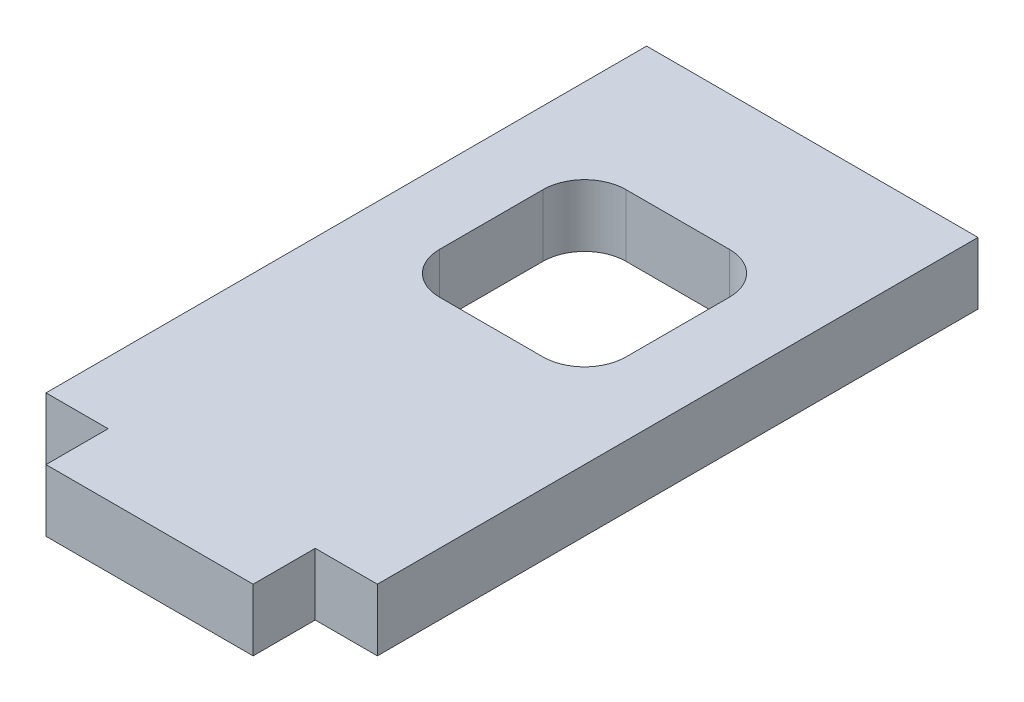
from build123d import *

# Parameters (mm, degrees)
SKETCH1_W               = 16
SKETCH1_H               = 29
BOSS_EXTRUDE1_DEPTH     = 1.5
SKETCH2_W               = 10
SKETCH2_H               = 3
BOSS_EXTRUDE2_DEPTH     = 1.5
SKETCH3_W               = 9
SKETCH3_H               = 9
CUT_EXTRUDE1_DEPTH      = 2.5
CUT_EXTRUDE1_DEPTH_BACK = 2.5
FILLET1_R               = 2


with BuildPart() as part:
    # Sketch1 → Boss-Extrude1 (new body, symmetric)
    with BuildSketch(Plane(origin=(0, 0, 0), x_dir=(1, 0, 0), z_dir=(0, 1, 0))):
        Rectangle(SKETCH1_W, SKETCH1_H)
    extrude(amount=BOSS_EXTRUDE1_DEPTH, both=True)

    # Sketch2 → Boss-Extrude2 (add, symmetric)
    with BuildSketch(Plane(origin=(0, 0, 0), x_dir=(1, 0, 0), z_dir=(0, 1, 0))):
        with Locations((0, -16)):
            Rectangle(SKETCH2_W, SKETCH2_H)
    extrude(amount=BOSS_EXTRUDE2_DEPTH, both=True)

    # Sketch3 → Cut-Extrude1 (cut, two sides)
    with BuildSketch(Plane(origin=(0, 0, 0), x_dir=(1, 0, 0), z_dir=(0, 1, 0))) as cut_extrude1_sk:
        with Locations((0, 3.5)):
            Rectangle(SKETCH3_W, SKETCH3_H)
    extrude(amount=CUT_EXTRUDE1_DEPTH, mode=Mode.SUBTRACT)
    extrude(cut_extrude1_sk.sketch, amount=-CUT_EXTRUDE1_DEPTH_BACK, mode=Mode.SUBTRACT)

    # Fillet1
    fillet1_edges = [part.edges().sort_by_distance(p)[0] for p in [
        (-4.5, 0, 1),
        (-4.5, 0, -8),
        (4.5, 0, -8),
        (4.5, 0, 1),
    ]]
    fillet(fillet1_edges, radius=FILLET1_R)


solid = part.part
